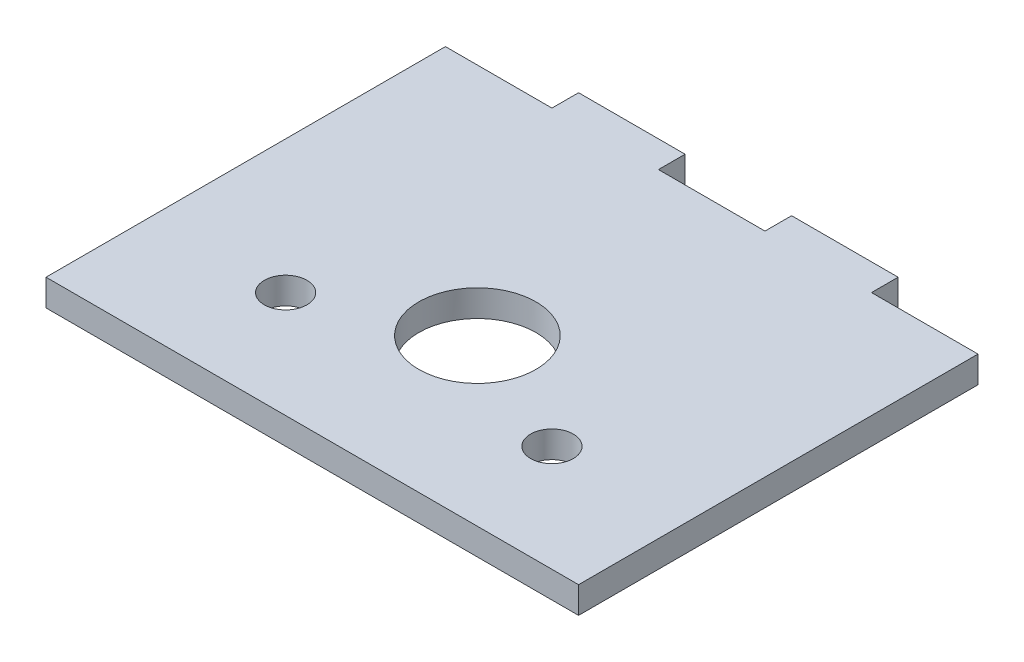
from build123d import *

# Parameters (mm, degrees)
SKETCH1_R           = 4
BOSS_EXTRUDE1_DEPTH = 5
CUT_EXTRUDE1_REACH  = 7
SKETCH2_R           = 11


with BuildPart() as part:
    # Sketch1 → Boss-Extrude1 (new body)
    with BuildSketch(Plane(origin=(0, 0, 0), x_dir=(1, 0, 0), z_dir=(0, 1, 0))):
        Polygon((-50, 44), (-30, 44), (-30, 49), (-10, 49), (-10, 44), (10, 44), (10, 49), (30, 49), (30, 44), (50, 44), (50, -31), (-50, -31), align=None)
        Circle(SKETCH1_R, mode=Mode.SUBTRACT)
        with Locations((25, -11)):
            Circle(SKETCH1_R, mode=Mode.SUBTRACT)
        with Locations((-25, -11)):
            Circle(SKETCH1_R, mode=Mode.SUBTRACT)
    extrude(amount=BOSS_EXTRUDE1_DEPTH)

    # Sketch2 → Cut-Extrude1 (cut, up to next)
    with BuildSketch(Plane(origin=(0, 5, 0), x_dir=(1, 0, 0), z_dir=(0, 1, 0)), mode=Mode.PRIVATE) as cut_extrude1_sk1:
        Circle(SKETCH2_R)
    cut_extrude1_tool1 = extrude(cut_extrude1_sk1.sketch, amount=-CUT_EXTRUDE1_REACH, mode=Mode.PRIVATE) & part.part
    add(cut_extrude1_tool1.solids().sort_by_distance((0, 5, 0))[0], mode=Mode.SUBTRACT)


solid = part.part
